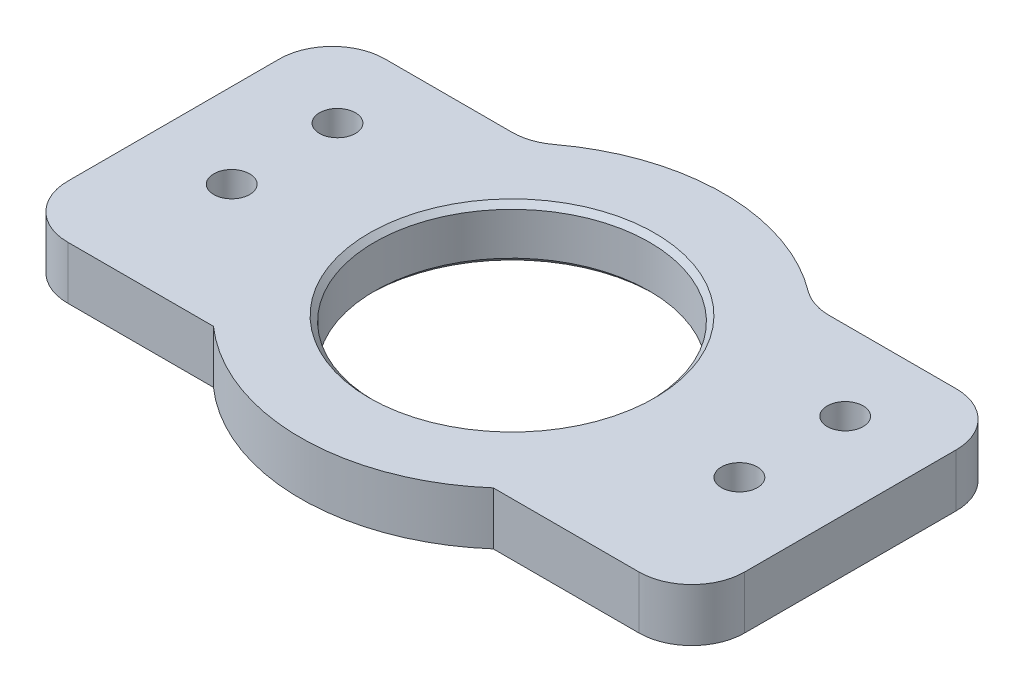
from build123d import *

# Parameters (mm, degrees)
EXTRUDE_1_DEPTH     = 5
SKETCH_2_R          = 13
CUT_EXTRUDE_1_DEPTH = 5
FILLET_1_R          = 5
HOLE_WIZARD_M3_1_D  = 3.4
CHAMFER1_SIZE       = 0.5


with BuildPart() as part:
    # 草图1 → 凸台-拉伸1 (new body)
    with BuildSketch(Plane(origin=(0, 0, 0), x_dir=(1, 0, 0), z_dir=(0, 1, 0))):
        with BuildLine():
            Line((45.228756555, 30), (64, 30))
            Line((64, 30), (64, 0))
            Line((64, 0), (45.228756555, 0))
            ThreePointArc((45.228756555, 0), (32, -5), (18.771243445, 0))
            Line((18.771243445, 0), (0, 0))
            Line((0, 0), (0, 30))
            Line((0, 30), (18.771243445, 30))
            ThreePointArc((18.771243445, 30), (32, 35), (45.228756555, 30))
        make_face()
    extrude(amount=EXTRUDE_1_DEPTH)

    # 草图2 → 切除-拉伸1 (cut)
    with BuildSketch(Plane(origin=(0, 5, 0), x_dir=(1, 0, 0), z_dir=(0, 1, 0))):
        with Locations((32, 15)):
            Circle(SKETCH_2_R)
    extrude(amount=-CUT_EXTRUDE_1_DEPTH, mode=Mode.SUBTRACT)

    # 圆角1
    fillet_1_edges = [part.edges().sort_by_distance(p)[0] for p in [
        (0, 2.5, -30),
        (18.771243445, 2.5, -30),
        (45.228756555, 2.5, -30),
        (64, 2.5, -30),
        (64, 2.5, 0),
        (0, 2.5, 0),
    ]]
    fillet(fillet_1_edges, radius=FILLET_1_R)

    # M3 间隙孔1 (through all)
    with Locations(Plane(origin=(0, 0, 0), x_dir=(-1, 0, 0), z_dir=(0, -1, 0))):
        with Locations((-56, 22.5), (-56, 12.5), (-8, 22.5), (-8, 12.5)):
            Hole(HOLE_WIZARD_M3_1_D / 2)

    # Chamfer1
    chamfer1_edges = [part.edges().sort_by_distance(p)[0] for p in [
        (19, 0, -15),
        (19, 5, -15),
    ]]
    chamfer(chamfer1_edges, length=CHAMFER1_SIZE)


solid = part.part
